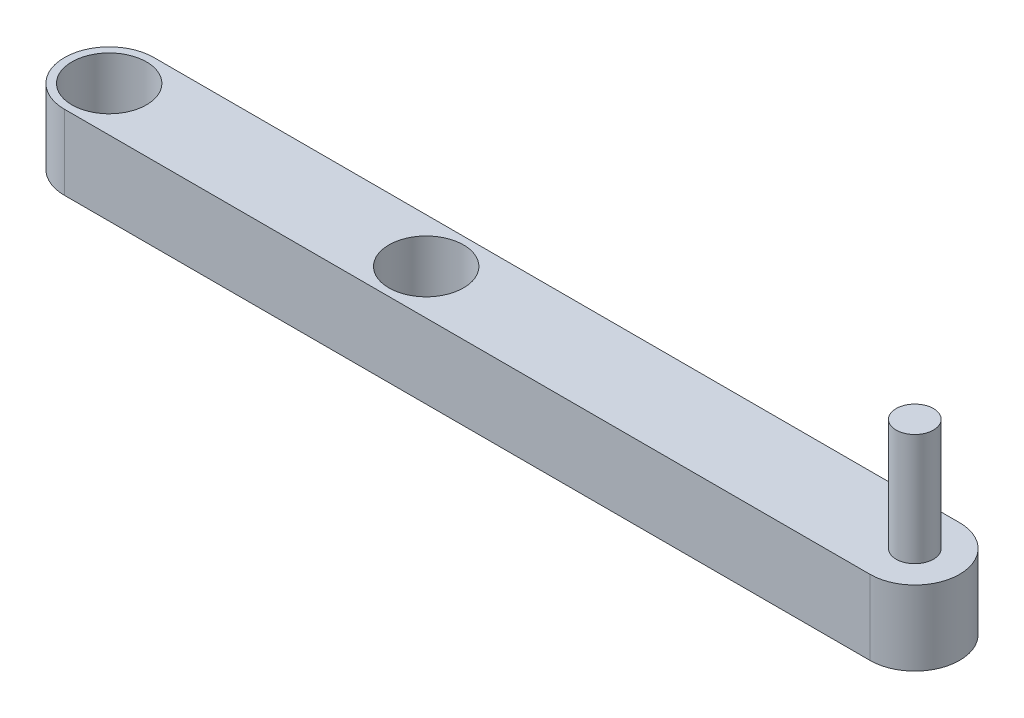
from build123d import *

# Parameters (mm, degrees)
SKETCH1_R           = 5
BOSS_EXTRUDE1_DEPTH = 10
SKETCH2_R           = 2.5
BOSS_EXTRUDE2_DEPTH = 15


with BuildPart() as part:
    # Sketch1 → Boss-Extrude1 (new body)
    with BuildSketch(Plane(origin=(0, 0, 0), x_dir=(1, 0, 0), z_dir=(0, 1, 0))):
        with BuildLine():
            Line((0, 6), (108, 6))
            ThreePointArc((108, 6), (114, 0), (108, -6))
            Line((108, -6), (0, -6))
            ThreePointArc((0, -6), (-6, 0), (0, 6))
        make_face()
        Circle(SKETCH1_R, mode=Mode.SUBTRACT)
        with Locations((42.5, 0)):
            Circle(SKETCH1_R, mode=Mode.SUBTRACT)
    extrude(amount=BOSS_EXTRUDE1_DEPTH)

    # Sketch2 → Boss-Extrude2 (add)
    with BuildSketch(Plane(origin=(0, 10, 0), x_dir=(1, 0, 0), z_dir=(0, 1, 0))):
        with Locations((108, 0)):
            Circle(SKETCH2_R)
    extrude(amount=BOSS_EXTRUDE2_DEPTH)


solid = part.part
